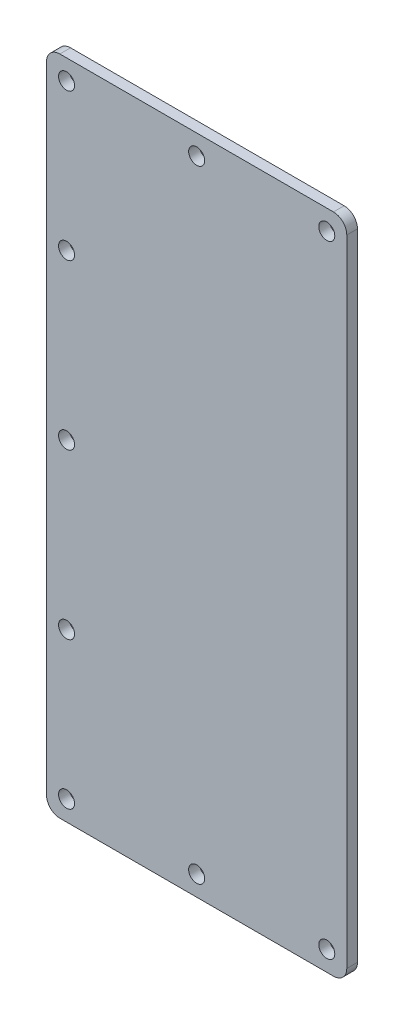
from build123d import *

# Parameters (mm, degrees)
EXTRUDE_1_DEPTH     = 8
SKETCH_2_R          = 6
CUT_EXTRUDE_1_DEPTH = 10


with BuildPart() as part:
    # 草图1 → 凸台-拉伸1 (new body)
    with BuildSketch(Plane.XY):
        with BuildLine():
            Line((10, 0), (215, 0))
            ThreePointArc((215, 0), (222.071067812, 2.928932188), (225, 10))
            Line((225, 10), (225, 486))
            ThreePointArc((225, 486), (222.071067812, 493.071067812), (215, 496))
            Line((215, 496), (10, 496))
            ThreePointArc((10, 496), (2.928932188, 493.071067812), (0, 486))
            Line((0, 486), (0, 10))
            ThreePointArc((0, 10), (2.928932188, 2.928932188), (10, 0))
        make_face()
    extrude(amount=EXTRUDE_1_DEPTH)

    # 草图2 → 切除-拉伸1 (cut)
    with BuildSketch(Plane.XY.offset(8)):
        with Locations((112.5, 481)):
            Circle(SKETCH_2_R)
        with Locations((210, 481)):
            Circle(SKETCH_2_R)
        with Locations((15, 481)):
            Circle(SKETCH_2_R)
        with Locations((15, 15)):
            Circle(SKETCH_2_R)
        with Locations((210, 15)):
            Circle(SKETCH_2_R)
        with Locations((112.5, 15)):
            Circle(SKETCH_2_R)
        with Locations((15, 248)):
            Circle(SKETCH_2_R)
        with Locations((15, 371)):
            Circle(SKETCH_2_R)
        with Locations((15, 125)):
            Circle(SKETCH_2_R)
    extrude(amount=-CUT_EXTRUDE_1_DEPTH, mode=Mode.SUBTRACT)


solid = part.part
